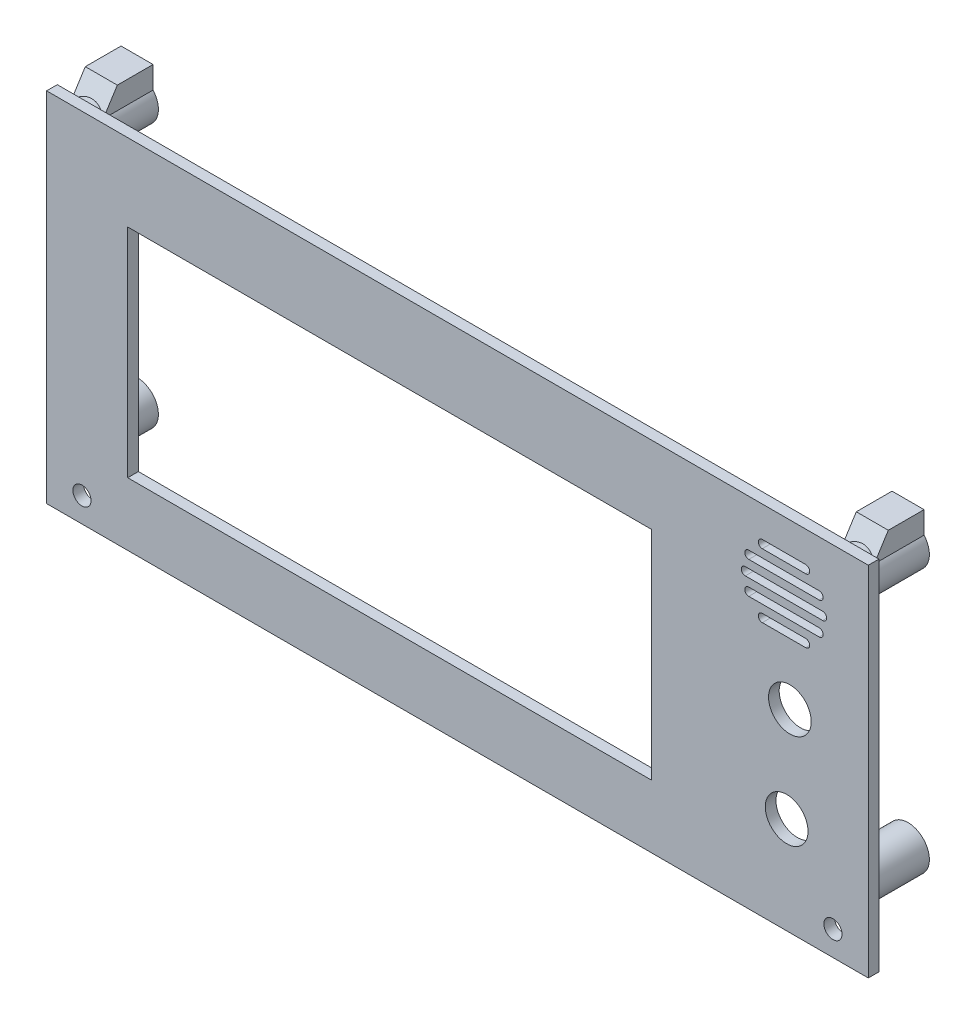
from build123d import *

# Parameters (mm, degrees)
SKETCH1_W           = 154
SKETCH1_H           = 67
SKETCH1_R           = 4
SKETCH1_W_2         = 98.2
SKETCH1_H_2         = 40.7
BOSS_EXTRUDE1_DEPTH = 2
SKETCH2_R           = 4
SKETCH2_R_2         = 1.3
BOSS_EXTRUDE2_DEPTH = 10.2
BOSS_EXTRUDE3_DEPTH = 3
BOSS_EXTRUDE4_DEPTH = 3
SKETCH4_R           = 1.7
CUT_EXTRUDE1_DEPTH  = 2


with BuildPart() as part:
    # Sketch1 → Boss-Extrude1 (new body)
    with BuildSketch(Plane(origin=(0, 0, -3.9), x_dir=(-1, 0, 0), z_dir=(0, 0, -1))):
        Rectangle(SKETCH1_W, SKETCH1_H)
        with Locations((-61.7, -15.35)):
            Circle(SKETCH1_R, mode=Mode.SUBTRACT)
        with Locations((-62.3, 2.75)):
            Circle(SKETCH1_R, mode=Mode.SUBTRACT)
        with BuildLine():
            Line((-57.130294851, 15.75), (-65.269705149, 15.75))
            ThreePointArc((-65.269705149, 15.75), (-66.019705149, 15), (-65.269705149, 14.25))
            Line((-65.269705149, 14.25), (-57.130294851, 14.25))
            ThreePointArc((-57.130294851, 14.25), (-56.380294851, 15), (-57.130294851, 15.75))
        make_face(mode=Mode.SUBTRACT)
        with BuildLine():
            Line((-65.269705149, 27.75), (-57.130294851, 27.75))
            ThreePointArc((-57.130294851, 27.75), (-56.380294851, 27), (-57.130294851, 26.25))
            Line((-57.130294851, 26.25), (-65.269705149, 26.25))
            ThreePointArc((-65.269705149, 26.25), (-66.019705149, 27), (-65.269705149, 27.75))
        make_face(mode=Mode.SUBTRACT)
        with BuildLine():
            Line((-68.45, 21.75), (-53.95, 21.75))
            ThreePointArc((-53.95, 21.75), (-53.2, 21), (-53.95, 20.25))
            Line((-53.95, 20.25), (-68.45, 20.25))
            ThreePointArc((-68.45, 20.25), (-69.2, 21), (-68.45, 21.75))
        make_face(mode=Mode.SUBTRACT)
        with BuildLine():
            Line((-54.599810609, 18.75), (-67.800189391, 18.75))
            ThreePointArc((-67.800189391, 18.75), (-68.550189391, 18), (-67.800189391, 17.25))
            Line((-67.800189391, 17.25), (-54.599810609, 17.25))
            ThreePointArc((-54.599810609, 17.25), (-53.849810609, 18), (-54.599810609, 18.75))
        make_face(mode=Mode.SUBTRACT)
        with BuildLine():
            Line((-54.599810609, 23.25), (-67.800189391, 23.25))
            ThreePointArc((-67.800189391, 23.25), (-68.550189391, 24), (-67.800189391, 24.75))
            Line((-67.800189391, 24.75), (-54.599810609, 24.75))
            ThreePointArc((-54.599810609, 24.75), (-53.849810609, 24), (-54.599810609, 23.25))
        make_face(mode=Mode.SUBTRACT)
        with Locations((12.7, -1.35)):
            Rectangle(SKETCH1_W_2, SKETCH1_H_2, mode=Mode.SUBTRACT)
    extrude(amount=-BOSS_EXTRUDE1_DEPTH)

    # Sketch2 → Boss-Extrude2 (add)
    with BuildSketch(Plane(origin=(0, 0, -3.9), x_dir=(-1, 0, 0), z_dir=(0, 0, -1))):
        with Locations((-72.25, 28.75)):
            Circle(SKETCH2_R)
        with Locations((-72.25, 28.75)):
            Circle(SKETCH2_R_2, mode=Mode.SUBTRACT)
        with Locations((-72.25, -20.75)):
            Circle(SKETCH2_R)
        with Locations((-72.25, -20.75)):
            Circle(SKETCH2_R_2, mode=Mode.SUBTRACT)
        with Locations((72.25, -20.75)):
            Circle(SKETCH2_R)
        with Locations((72.25, -20.75)):
            Circle(SKETCH2_R_2, mode=Mode.SUBTRACT)
        with Locations((72.25, 28.75)):
            Circle(SKETCH2_R)
        with Locations((72.25, 28.75)):
            Circle(SKETCH2_R_2, mode=Mode.SUBTRACT)
    extrude(amount=BOSS_EXTRUDE2_DEPTH)

    # Sketch3 → Boss-Extrude3 (add, symmetric)
    with BuildSketch(Plane.ZY.offset(72.25)):
        Polygon((-7.4, 35.55), (-3.9, 30.05), (-14.1, 30.05), (-14.1, 35.55), align=None)
    extrude(amount=BOSS_EXTRUDE3_DEPTH, both=True)

    # Sketch5 → Boss-Extrude4 (add, symmetric)
    with BuildSketch(Plane(origin=(72.25, 0, 0), x_dir=(0, 0, -1), z_dir=(1, 0, 0))):
        Polygon((3.9, 30.05), (7.4, 35.55), (14.1, 35.55), (14.1, 30.05), align=None)
    extrude(amount=BOSS_EXTRUDE4_DEPTH, both=True)

    # Sketch4 → Cut-Extrude1 (cut)
    with BuildSketch(Plane.XY.offset(-1.9)):
        with Locations((-70.376631043, -28.876631043)):
            Circle(SKETCH4_R)
        with Locations((70.376631043, -28.876631043)):
            Circle(SKETCH4_R)
    extrude(amount=-CUT_EXTRUDE1_DEPTH, mode=Mode.SUBTRACT)


solid = part.part
